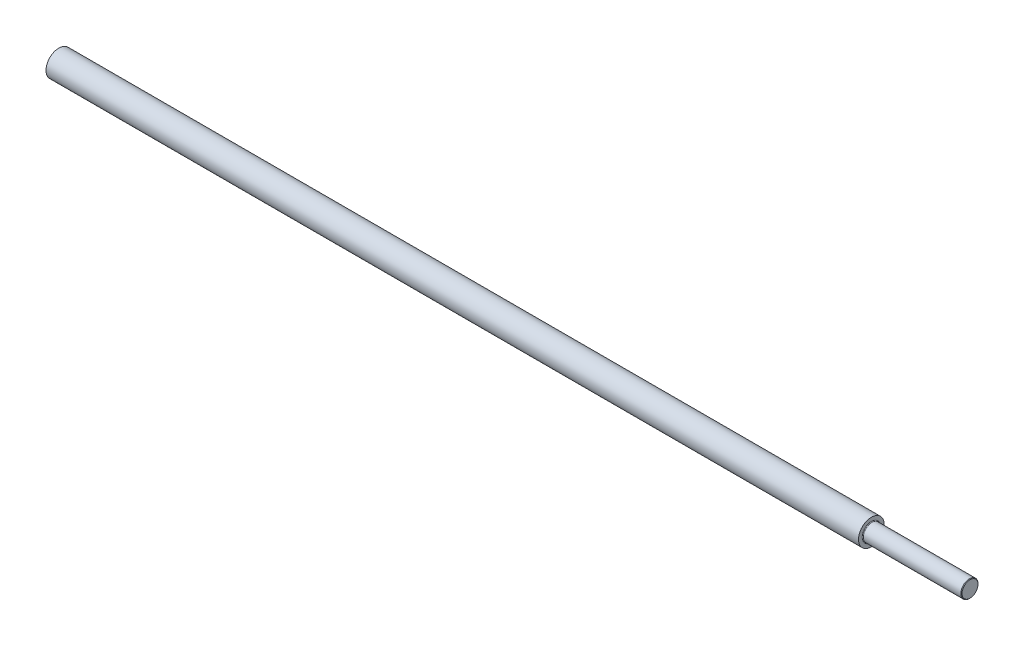
from build123d import *


with BuildPart() as part:
    # Sketch1 → Revolve1 (revolve)
    with BuildSketch(Plane.XY):
        with BuildLine():
            Line((0, 0), (0, 6))
            Line((0, 6), (379, 6))
            Line((379, 6), (379, 4.3))
            ThreePointArc((379, 4.3), (379.087867966, 4.087867966), (379.3, 4))
            Line((379.3, 4), (424.733333333, 4))
            Line((424.733333333, 4), (425, 3.733333333))
            Line((425, 3.733333333), (425, 0))
            Line((425, 0), (0, 0))
        make_face()
    revolve(axis=Axis((425, 0, 0), (-1, 0, 0)))


solid = part.part
